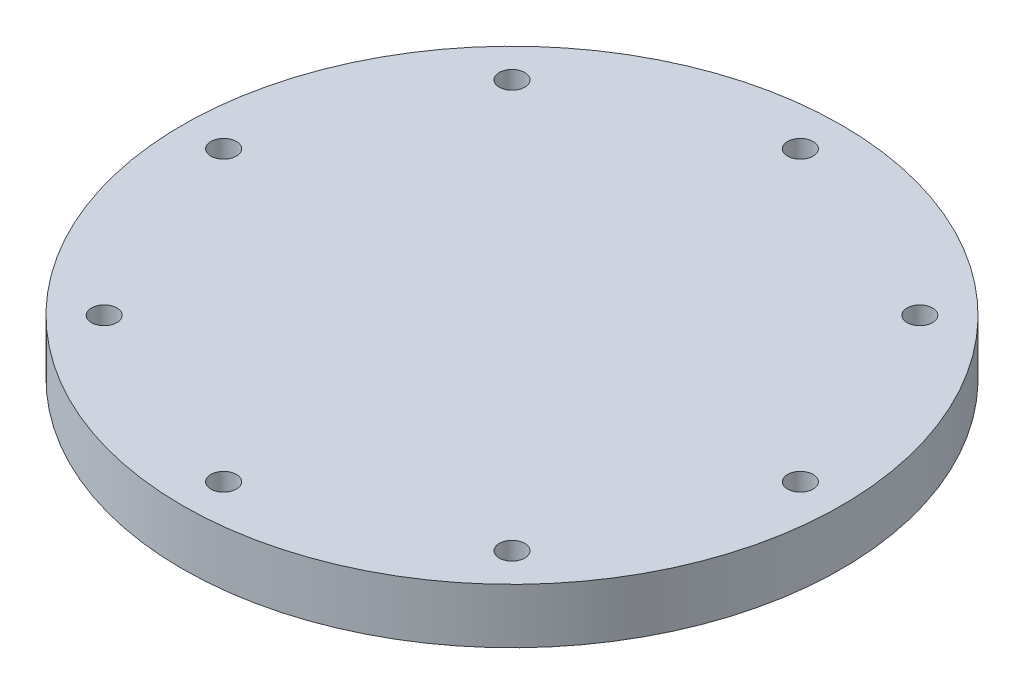
from build123d import *

# Parameters (mm, degrees)
SKETCH1_R                                      = 38.1
BOSS_EXTRUDE1_DEPTH                            = 6.35
CBORE_FOR_4_BUTTON_HEAD_CAP_SCREW1_D           = 2.9464
CBORE_FOR_4_BUTTON_HEAD_CAP_SCREW1_CBORE_D     = 4.826
CBORE_FOR_4_BUTTON_HEAD_CAP_SCREW1_CBORE_DEPTH = 2.8448
CIRPATTERN1_COUNT                              = 8


with BuildPart() as part:
    # Sketch1 → Boss-Extrude1 (new body)
    with BuildSketch(Plane(origin=(0, 0, 0), x_dir=(1, 0, 0), z_dir=(0, 1, 0))):
        Circle(SKETCH1_R)
    extrude(amount=BOSS_EXTRUDE1_DEPTH)

    # CBORE for #4 Button Head Cap Screw1 (through all)
    with Locations(Plane(origin=(0, 0, 0), x_dir=(-1, 0, 0), z_dir=(0, -1, 0))):
        with Locations((0, -33.3375)):
            cbore_for_4_button_head_cap_screw1 = CounterBoreHole(CBORE_FOR_4_BUTTON_HEAD_CAP_SCREW1_D / 2, CBORE_FOR_4_BUTTON_HEAD_CAP_SCREW1_CBORE_D / 2, CBORE_FOR_4_BUTTON_HEAD_CAP_SCREW1_CBORE_DEPTH)

    # CirPattern1: CBORE for #4 Button Head Cap Screw1 ×8 about axis
    cirpattern1_axis = Axis((0, 0, 0), (0, 1, 0))
    for i in range(1, CIRPATTERN1_COUNT):
        add(cbore_for_4_button_head_cap_screw1.rotate(cirpattern1_axis, i * 360 / CIRPATTERN1_COUNT), mode=Mode.SUBTRACT)


solid = part.part
